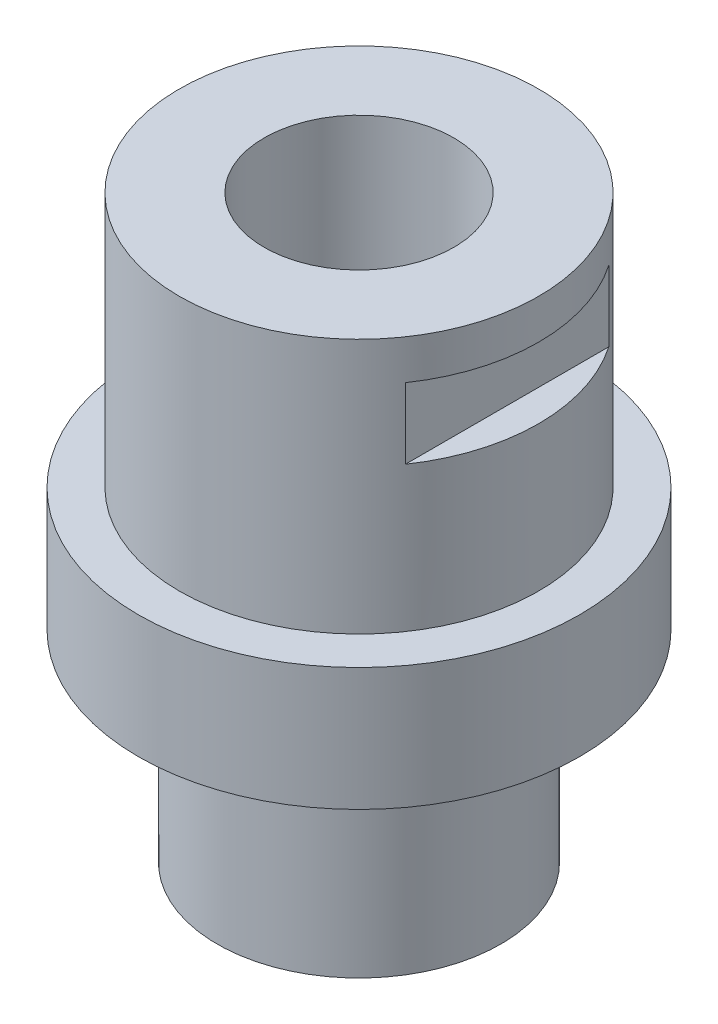
from build123d import *

# Parameters (mm, degrees)
SKETCH1_R            = 35
BOSS_EXTRUDE1_DEPTH  = 92
SKETCH2_OUTSIDE_W    = 99.028
SKETCH2_OUTSIDE_H    = 99.028
SKETCH2_OUTSIDE_R    = 28.5
CUT_EXTRUDE1_DEPTH   = 40.5
SKETCH3_OUTSIDE_W    = 99.028
SKETCH3_OUTSIDE_H    = 99.028
SKETCH3_OUTSIDE_R    = 22.5
CUT_EXTRUDE2_DEPTH   = 32
SKETCH4_R            = 15.05
CUT_EXTRUDE3_DEPTH   = 93
SKETCH5_W            = 5
SKETCH5_H            = 11.2
TESTINGFEATURE_DEPTH = 36


with BuildPart() as part:
    # Sketch1 → Boss-Extrude1 (new body)
    with BuildSketch(Plane(origin=(0, 0, 0), x_dir=(1, 0, 0), z_dir=(0, 1, 0))):
        Circle(SKETCH1_R)
    extrude(amount=BOSS_EXTRUDE1_DEPTH)

    # Sketch2 outside → Cut-Extrude1 (cut)
    with BuildSketch(Plane(origin=(0, 92, 0), x_dir=(1, 0, 0), z_dir=(0, 1, 0))):
        Rectangle(SKETCH2_OUTSIDE_W, SKETCH2_OUTSIDE_H)
        Circle(SKETCH2_OUTSIDE_R, mode=Mode.SUBTRACT)
    extrude(amount=-CUT_EXTRUDE1_DEPTH, mode=Mode.SUBTRACT)

    # Sketch3 outside → Cut-Extrude2 (cut)
    with BuildSketch(Plane.XZ):
        Rectangle(SKETCH3_OUTSIDE_W, SKETCH3_OUTSIDE_H)
        Circle(SKETCH3_OUTSIDE_R, mode=Mode.SUBTRACT)
    extrude(amount=-CUT_EXTRUDE2_DEPTH, mode=Mode.SUBTRACT)

    # Sketch4 → Cut-Extrude3 (cut, through all)
    with BuildSketch(Plane.XZ):
        Circle(SKETCH4_R)
    extrude(amount=-CUT_EXTRUDE3_DEPTH, mode=Mode.SUBTRACT)

    # Sketch5 → TestingFeature (cut, symmetric)
    with BuildSketch(Plane.XY):
        with Locations((26, 80.1)):
            Rectangle(SKETCH5_W, SKETCH5_H)
    testingfeature = extrude(amount=TESTINGFEATURE_DEPTH, both=True, mode=Mode.SUBTRACT)

    # Mirror1: TestingFeature across plane
    add(testingfeature.mirror(Plane(origin=(0, 0, 0), x_dir=(0, 0, 1), z_dir=(1, 0, 0))), mode=Mode.SUBTRACT)


solid = part.part
